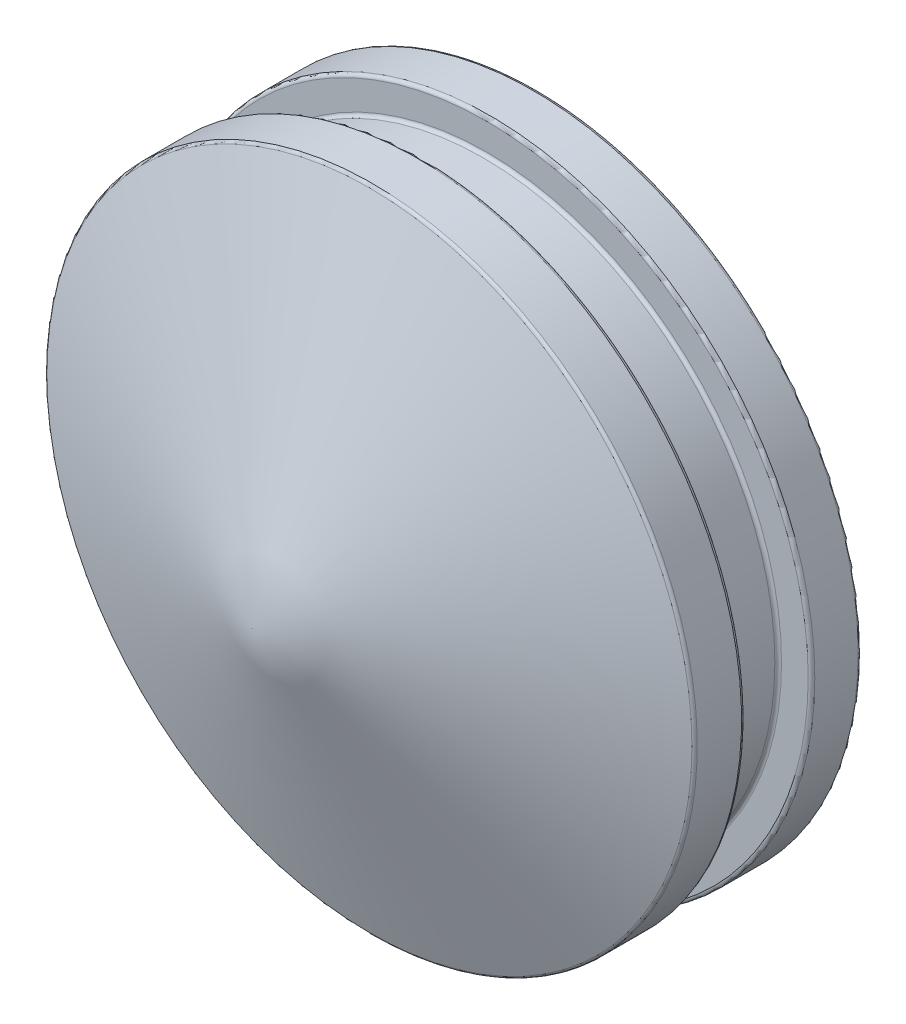
from build123d import *

# Parameters (mm, degrees)
FILLET1_R = 0.1


with BuildPart() as part:
    # Sketch1 → Revolve1 (revolve)
    with BuildSketch(Plane(origin=(0, 0, 0), x_dir=(1, 0, 0), z_dir=(0, 1, 0))):
        Polygon((9.75, 3.548709784), (9.75, 5.048709784), (8.75, 5.048709784), (8.75, 7.048709784), (9.75, 7.048709784), (9.75, 8.548709784), (4, 8.548709784), (4, 6.048709784), (5, 6.048709784), (5, 4.548709784), (0, 4.548709784), (0, 0), align=None)
    revolve(axis=Axis((0, 0, 1000), (0, 0, -1)))

    # Fillet1
    fillet1_edges = [part.edges().sort_by_distance(p)[0] for p in [
        (-5, 0, -4.548709784),
        (-5, 0, -6.048709784),
        (-4, 0, -6.048709784),
        (-4, 0, -8.548709784),
        (-9.75, 0, -8.548709784),
        (-9.75, 0, -7.048709784),
        (-8.75, 0, -7.048709784),
        (-8.75, 0, -5.048709784),
        (-9.75, 0, -5.048709784),
        (-9.75, 0, -3.548709784),
    ]]
    fillet(fillet1_edges, radius=FILLET1_R)


solid = part.part
